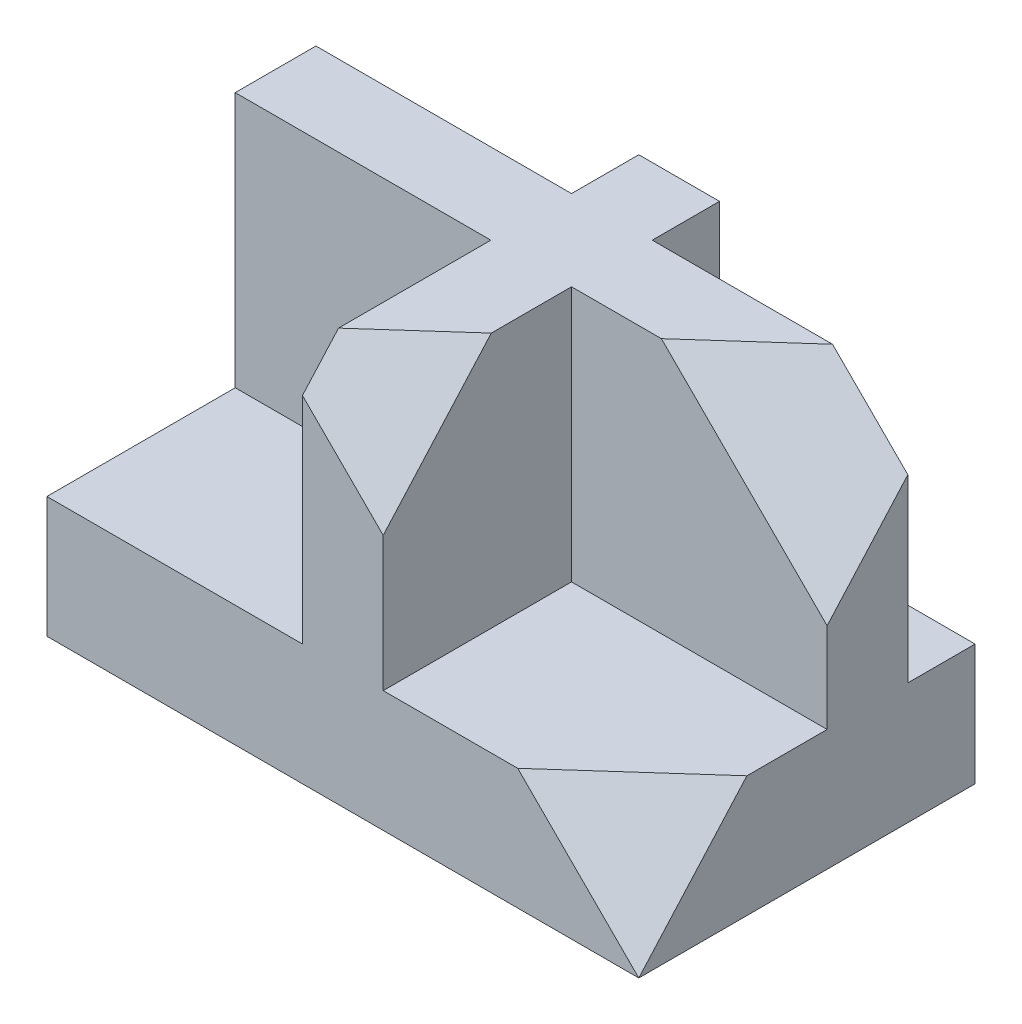
from build123d import *

# Parameters (mm, degrees)
SKETCH2_W           = 88
SKETCH2_H           = 50
BOSS_EXTRUDE1_DEPTH = 18
BOSS_EXTRUDE2_DEPTH = 38
CUT_EXTRUDE14_DEPTH = 38


with BuildPart() as part:
    # Sketch2 → Boss-Extrude1 (new body)
    with BuildSketch(Plane(origin=(0, 0, 0), x_dir=(1, 0, 0), z_dir=(0, 1, 0))):
        Rectangle(SKETCH2_W, SKETCH2_H)
    extrude(amount=BOSS_EXTRUDE1_DEPTH)

    # Sketch3 → Boss-Extrude2 (add)
    with BuildSketch(Plane(origin=(0, 18, 0), x_dir=(1, 0, 0), z_dir=(0, 1, 0))):
        Polygon((-6, 25), (-6, 15), (-44, 15), (-44, 3), (-6, 3), (-6, -25), (6, -25), (6, 3), (44, 3), (44, 15), (6, 15), (6, 25), align=None)
    extrude(amount=BOSS_EXTRUDE2_DEPTH)

    # Sketch7 → Cut-Extrude14 (cut)
    with BuildSketch(Plane(origin=(22.123893805, 22.123893805, 24.778761062), x_dir=(0.832300245, -0.36918925, -0.41349196), z_dir=(0.554325088, 0.554325088, 0.620844098))):
        Polygon((-40.999499912, 25.122114818), (26.28391177, -16.650394233), (26.28391177, 58.422903284), align=None)
    extrude(amount=CUT_EXTRUDE14_DEPTH, mode=Mode.SUBTRACT)


solid = part.part
